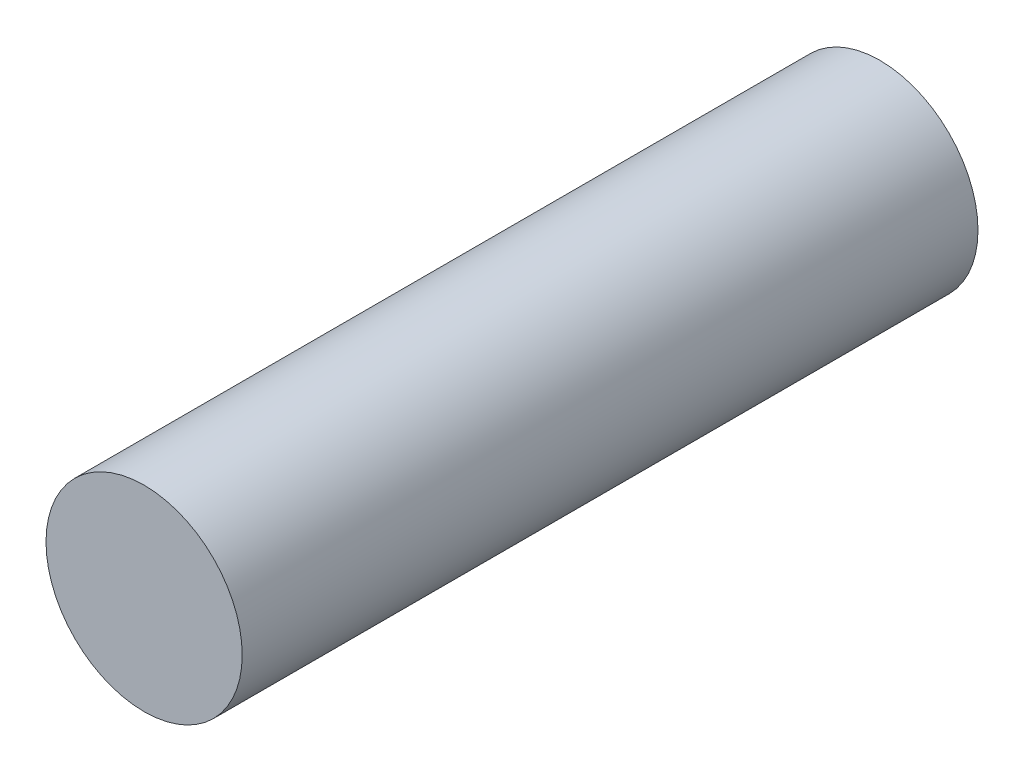
from build123d import *

# Parameters (mm, degrees)
SKETCH1_R           = 2
BOSS_EXTRUDE1_DEPTH = 15


with BuildPart() as part:
    # Sketch1 → Boss-Extrude1 (new body)
    with BuildSketch(Plane.XY):
        Circle(SKETCH1_R)
    extrude(amount=BOSS_EXTRUDE1_DEPTH)


solid = part.part
